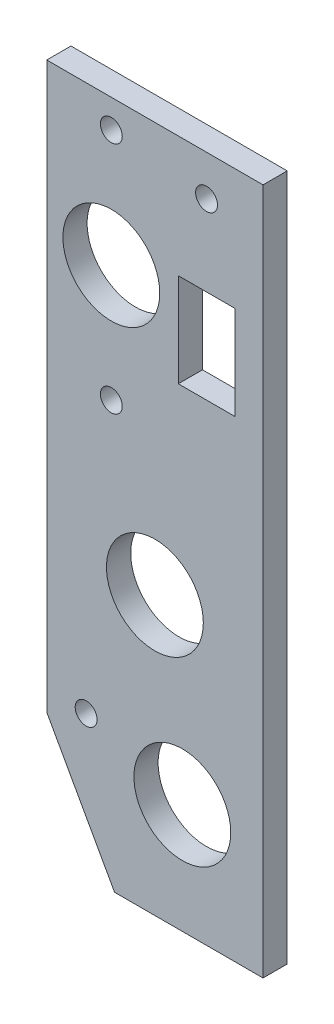
from build123d import *

# Parameters (mm, degrees)
BOSS_EXTRUDE1_DEPTH         = 4.7625
F_3_4_0_75_DIAMETER_HOLE1_D = 19.05
SKETCH4_W                   = 11.1125
SKETCH4_H                   = 18.415
CUT_EXTRUDE1_DEPTH          = 5.7625
F_6_CLEARANCE_HOLE1_D       = 4.3053


with BuildPart() as part:
    # Sketch1 → Boss-Extrude1 (new body)
    with BuildSketch(Plane.XY):
        Polygon((-44.1325, -84.1375), (-30.7975, -108.1405), (-1.5875, -108.1405), (-1.5875, 26.9875), (-44.1325, 26.9875), align=None)
    extrude(amount=BOSS_EXTRUDE1_DEPTH)

    # 3/4 (0.75) Diameter Hole1 (through all)
    with Locations(Plane.XY.offset(4.7625)):
        with Locations((-31.4325, -1.620345612), (-17.4625, -86.5505), (-22.86, -53.5305)):
            Hole(F_3_4_0_75_DIAMETER_HOLE1_D / 2)

    # Sketch4 → Cut-Extrude1 (cut, through all)
    with BuildSketch(Plane.XY.offset(4.7625)):
        with Locations((-12.7, -6.0325)):
            Rectangle(SKETCH4_W, SKETCH4_H)
    extrude(amount=-CUT_EXTRUDE1_DEPTH, mode=Mode.SUBTRACT)

    # #6 Clearance Hole1 (through all)
    with Locations(Plane.XY.offset(4.7625)):
        with Locations((-36.3855, -80.4545), (-12.7, 19.05), (-31.4325, 21.404754388), (-31.4325, -24.620045612)):
            Hole(F_6_CLEARANCE_HOLE1_D / 2)


solid = part.part
